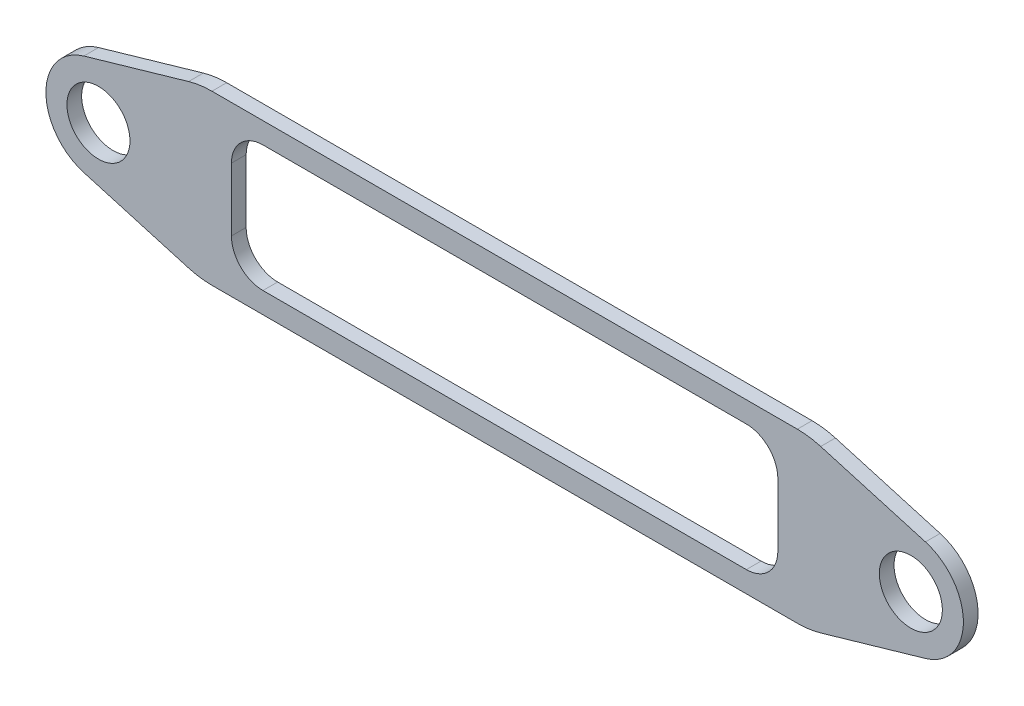
from build123d import *

# Parameters (mm, degrees)
SKETCH1_R           = 0.75
BOSS_EXTRUDE1_DEPTH = 0.35


with BuildPart() as part:
    # Sketch1 → Boss-Extrude1 (new body)
    with BuildSketch(Plane.XY):
        with BuildLine():
            Line((-5.814833275, -1.856361479), (8.113049614, -1.856361479))
            ThreePointArc((8.113049614, -1.856361479), (8.393561593, -1.836592028), (8.668528006, -1.777674508))
            Line((8.668528006, -1.777674508), (11.160598675, -1.057182122))
            ThreePointArc((11.160598675, -1.057182122), (12.06342468, 0.143638521), (11.160598675, 1.344459164))
            Line((11.160598675, 1.344459164), (8.668528006, 2.06495155))
            ThreePointArc((8.668528006, 2.06495155), (8.393561593, 2.123869071), (8.113049614, 2.143638521))
            Line((8.113049614, 2.143638521), (-5.814833275, 2.143638521))
            ThreePointArc((-5.814833275, 2.143638521), (-6.095345255, 2.123869071), (-6.370311667, 2.06495155))
            Line((-6.370311667, 2.06495155), (-8.862382336, 1.344459164))
            ThreePointArc((-8.862382336, 1.344459164), (-9.765208341, 0.143638521), (-8.862382336, -1.057182122))
            Line((-8.862382336, -1.057182122), (-6.370311667, -1.777674508))
            ThreePointArc((-6.370311667, -1.777674508), (-6.095345255, -1.836592028), (-5.814833275, -1.856361479))
        make_face()
        with Locations((-8.515208341, 0.143638521)):
            Circle(SKETCH1_R, mode=Mode.SUBTRACT)
        with Locations((10.81342468, 0.143638521)):
            Circle(SKETCH1_R, mode=Mode.SUBTRACT)
        with BuildLine():
            Line((7.649108169, -0.606361479), (7.649108169, 0.893638521))
            ThreePointArc((7.649108169, 0.893638521), (7.429438255, 1.423968607), (6.899108169, 1.643638521))
            Line((6.899108169, 1.643638521), (-4.600891831, 1.643638521))
            ThreePointArc((-4.600891831, 1.643638521), (-5.131221917, 1.423968607), (-5.350891831, 0.893638521))
            Line((-5.350891831, 0.893638521), (-5.350891831, -0.606361479))
            ThreePointArc((-5.350891831, -0.606361479), (-5.131221917, -1.136691565), (-4.600891831, -1.356361479))
            Line((-4.600891831, -1.356361479), (6.899108169, -1.356361479))
            ThreePointArc((6.899108169, -1.356361479), (7.429438255, -1.136691565), (7.649108169, -0.606361479))
        make_face(mode=Mode.SUBTRACT)
    extrude(amount=BOSS_EXTRUDE1_DEPTH)


solid = part.part
